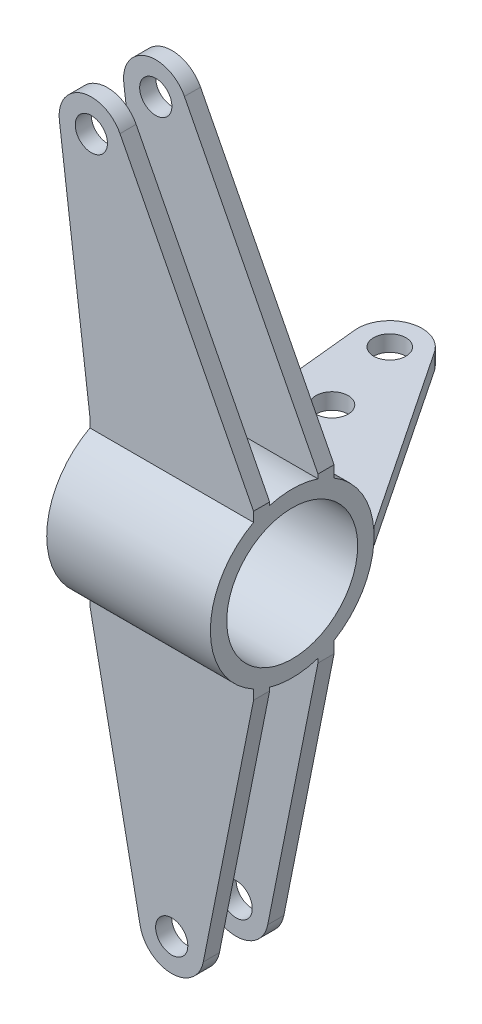
from build123d import *

# Parameters (mm, degrees)
SKETCH2_R             = 25.4
SKETCH2_R_2           = 20.32
BOSS_EXTRUDE1_DEPTH   = 25.4
BOSS_EXTRUDE2_START   = 7
SKETCH3_R             = 5
BOSS_EXTRUDE2_DEPTH   = 5
BOSS_EXTRUDE2_2_DEPTH = 5
BOSS_EXTRUDE4_START   = -13
SKETCH3_3_R           = 5
BOSS_EXTRUDE4_DEPTH   = 5
BOSS_EXTRUDE4_2_DEPTH = 5
BOSS_EXTRUDE5_DEPTH   = 25.4
SKETCH6_R             = 5
BOSS_EXTRUDE6_DEPTH   = 2.5


with BuildPart() as part:
    # Sketch2 → Boss-Extrude1 (new, symmetric)
    with BuildSketch(Plane(origin=(0, 0, 0), x_dir=(0, 0, -1), z_dir=(1, 0, 0))):
        Circle(SKETCH2_R)
        Circle(SKETCH2_R_2, mode=Mode.SUBTRACT)
    extrude(amount=BOSS_EXTRUDE1_DEPTH, both=True)



with BuildPart() as body_2:
    # Sketch3 → Boss-Extrude2 (new body)
    with BuildSketch(Plane.XY.offset(BOSS_EXTRUDE2_START)):
        with BuildLine():
            Line((-25.4, 25.4), (-34.870920337, 100.346276275))
            ThreePointArc((-34.870920337, 100.346276275), (-27.904518621, 111.153521469), (-16.053197995, 106.166187415))
            Line((-16.053197995, 106.166187415), (25.4, 25.4))
            Line((25.4, 25.4), (-25.4, 25.4))
        make_face()
        with Locations((-24.949822775, 101.6)):
            Circle(SKETCH3_R, mode=Mode.SUBTRACT)
    extrude(amount=BOSS_EXTRUDE2_DEPTH)


with BuildPart() as body_3:
    # Sketch3 → Boss-Extrude2 2 (new body)
    with BuildSketch(Plane.XY.offset(BOSS_EXTRUDE2_START)):
        with BuildLine():
            Line((-25.4, -25.4), (-9.806723533, -103.556571886))
            ThreePointArc((-9.806723533, -103.556571886), (0, -111.6), (9.806723533, -103.556571886))
            Line((9.806723533, -103.556571886), (25.4, -25.4))
            Line((25.4, -25.4), (-25.4, -25.4))
        make_face()
        with Locations((0, -101.6)):
            Circle(SKETCH3_R, mode=Mode.SUBTRACT)
    extrude(amount=BOSS_EXTRUDE2_2_DEPTH)


with BuildPart() as body_4:
    # Sketch3_3 → Boss-Extrude4 (new body)
    with BuildSketch(Plane.XY.offset(BOSS_EXTRUDE4_START)):
        with BuildLine():
            Line((-25.4, 25.4), (-34.870920337, 100.346276275))
            ThreePointArc((-34.870920337, 100.346276275), (-27.904518621, 111.153521469), (-16.053197995, 106.166187415))
            Line((-16.053197995, 106.166187415), (25.4, 25.4))
            Line((25.4, 25.4), (-25.4, 25.4))
        make_face()
        with Locations((-24.949822775, 101.6)):
            Circle(SKETCH3_3_R, mode=Mode.SUBTRACT)
    extrude(amount=BOSS_EXTRUDE4_DEPTH)


with BuildPart() as body_5:
    # Sketch3_3 → Boss-Extrude4 2 (new body)
    with BuildSketch(Plane.XY.offset(BOSS_EXTRUDE4_START)):
        with BuildLine():
            Line((-25.4, -25.4), (-9.806723533, -103.556571886))
            ThreePointArc((-9.806723533, -103.556571886), (0, -111.6), (9.806723533, -103.556571886))
            Line((9.806723533, -103.556571886), (25.4, -25.4))
            Line((25.4, -25.4), (-25.4, -25.4))
        make_face()
        with Locations((0, -101.6)):
            Circle(SKETCH3_3_R, mode=Mode.SUBTRACT)
    extrude(amount=BOSS_EXTRUDE4_2_DEPTH)


with BuildPart() as part_1:
    add(part.part)

    add(body_2.part)  # Boss-Extrude5 merges body 2

    add(body_3.part)  # Boss-Extrude5 merges body 3

    add(body_4.part)  # Boss-Extrude5 merges body 4

    add(body_5.part)  # Boss-Extrude5 merges body 5
    # Sketch5 → Boss-Extrude5 (add, symmetric)
    with BuildSketch(Plane(origin=(0, 0, 0), x_dir=(0, 0, -1), z_dir=(1, 0, 0))):
        with BuildLine():
            Line((8, -25.4), (13, -25.4))
            Line((13, -25.4), (13, -21.821090715))
            ThreePointArc((13, -21.821090715), (10.562037818, -23.099856215), (8, -24.107260317))
            Line((8, -24.107260317), (8, -25.4))
        make_face()
        with BuildLine():
            Line((-12, -25.4), (-7, -25.4))
            Line((-7, -25.4), (-7, -24.416387939))
            ThreePointArc((-7, -24.416387939), (-9.554057075, -23.534655158), (-12, -22.386603137))
            Line((-12, -22.386603137), (-12, -25.4))
        make_face()
        with BuildLine():
            Line((-12, 25.4), (-7, 25.4))
            Line((-7, 25.4), (-7, 24.416387939))
            ThreePointArc((-7, 24.416387939), (-9.554057075, 23.534655158), (-12, 22.386603137))
            Line((-12, 22.386603137), (-12, 25.4))
        make_face()
        with BuildLine():
            Line((8, 25.4), (13, 25.4))
            Line((13, 25.4), (13, 21.821090715))
            ThreePointArc((13, 21.821090715), (10.562037818, 23.099856215), (8, 24.107260317))
            Line((8, 24.107260317), (8, 25.4))
        make_face()
    extrude(amount=BOSS_EXTRUDE5_DEPTH, both=True)


with BuildPart() as body_2_2:
    # Sketch6 → Boss-Extrude6 (new, symmetric)
    with BuildSketch(Plane(origin=(0, 0, 0), x_dir=(1, 0, 0), z_dir=(0, 1, 0))):
        with BuildLine():
            Line((-25.4, 25.4), (-30.466168735, 75.18767257))
            ThreePointArc((-30.466168735, 75.18767257), (-23.898598023, 85.611081427), (-12.199244226, 81.750309743))
            Line((-12.199244226, 81.750309743), (25.4, 25.4))
            Line((25.4, 25.4), (-25.4, 25.4))
        make_face()
        with Locations((-20.517541032, 76.2)):
            Circle(SKETCH6_R, mode=Mode.SUBTRACT)
        with Locations((-13.913567634, 51.673533981)):
            Circle(SKETCH6_R, mode=Mode.SUBTRACT)
    extrude(amount=BOSS_EXTRUDE6_DEPTH, both=True)


solid = Compound([part_1.part, body_2_2.part])
